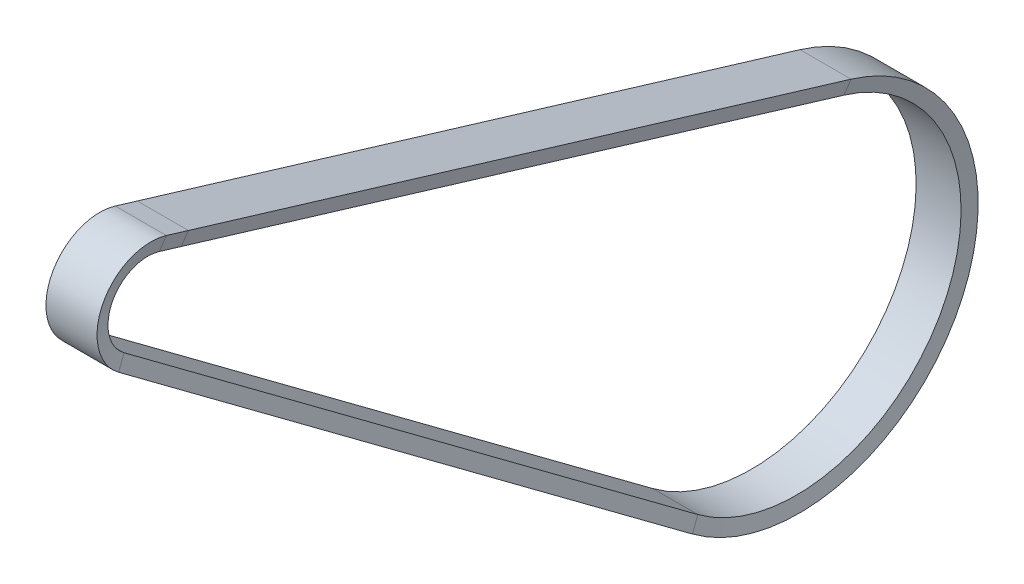
from build123d import *


with BuildPart() as part:
    # Sweep2: sweep along a path in Schizzo2
    with BuildLine(Plane(origin=(0, 0, 0), x_dir=(0, 0, -1), z_dir=(1, 0, 0))) as sweep2_path:
        Line((13.145484476, 85.493570144), (267.7362051, 8.553542371))
        ThreePointArc((267.7362051, 8.553542371), (304.754104599, -77.714587953), (213.39832656, -99.316370558))
        Line((213.39832656, -99.316370558), (0.035611501, 59.468246845))
        ThreePointArc((0.035611501, 59.468246845), (-4.343739367, 77.988894569), (13.145484476, 85.493570144))
    # Schizzo3D1 → Sweep2 (sweep)
    with BuildSketch(Plane(origin=(9.500289888, 88.002440666, -22.845650773), x_dir=(-1, 0, 0), z_dir=(0, 0.28929028421703545, 0.9572414175419004))):
        Polygon((0, 0), (19, 0), (17.855289888, 5.20775864), (1.145289888, 5.20775864), align=None)
    sweep(path=sweep2_path.line)


solid = part.part
